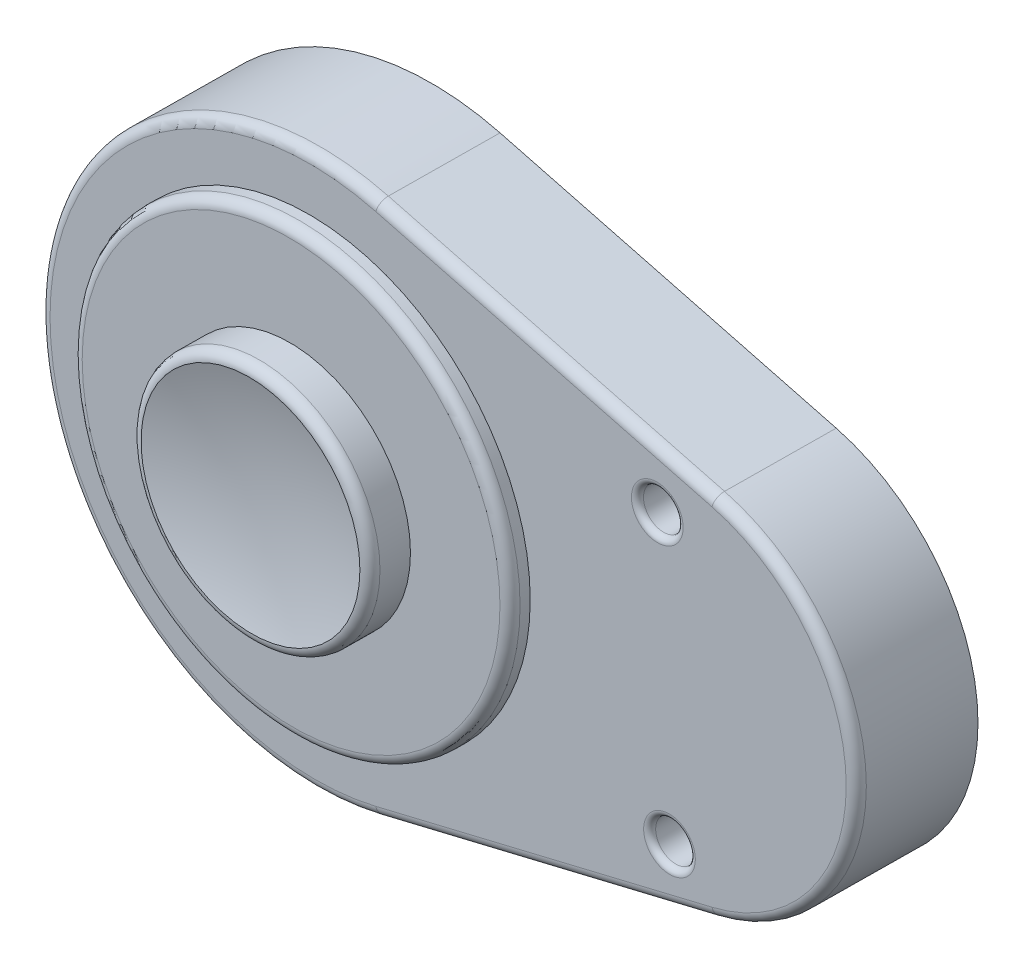
from build123d import *

# Parameters (mm, degrees)
BOSS_EXTRUDE1_DEPTH = 30
SKETCH2_R           = 55
BOSS_EXTRUDE2_DEPTH = 5
SKETCH3_R           = 30
BOSS_EXTRUDE3_DEPTH = 10
SKETCH4_R           = 5
CUT_EXTRUDE4_DEPTH  = 20
SKETCH5_R           = 3
CUT_EXTRUDE5_DEPTH  = 33.082590237
FILLET1_R           = 2.5
FILLET2_R           = 1.5
DOME1_FACE_RADIUS   = 27.5
DOME1_HEIGHT        = 4


with BuildPart() as part:
    # Sketch1 → Boss-Extrude1 (new body)
    with BuildSketch(Plane(origin=(-0.609266147, 0, 59.996906543), x_dir=(0.99993435, 0.005309042, 0.010154293), z_dir=(-0.010154436, 0, 0.999948442))):
        with BuildLine():
            Line((13.092334874, 339.479342253), (-71.283345055, 360.871198017))
            ThreePointArc((-71.283345055, 360.871198017), (-156.616646458, 294.835639545), (-71.989316722, 227.897740169))
            Line((-71.989316722, 227.897740169), (12.608744127, 248.392494546))
            ThreePointArc((12.608744127, 248.392494546), (48.482712148, 293.74674302), (13.092334874, 339.479342253))
        make_face()
    extrude(amount=BOSS_EXTRUDE1_DEPTH)

    # Sketch2 → Boss-Extrude2 (add)
    with BuildSketch(Plane(origin=(-0.91389922, 0, 89.995359815), x_dir=(0.99993435, 0.005309042, 0.010154293), z_dir=(-0.010154436, 0, 0.999948442))):
        with Locations((-88.433233056, 294.473645815)):
            Circle(SKETCH2_R)
    extrude(amount=BOSS_EXTRUDE2_DEPTH)

    # Sketch3 → Boss-Extrude3 (add)
    with BuildSketch(Plane(origin=(-0.964671399, 0, 94.995102027), x_dir=(0.99993435, 0.005309042, 0.010154293), z_dir=(-0.010154436, 0, 0.999948442))):
        with Locations((-88.433233056, 294.473645815)):
            Circle(SKETCH3_R)
    extrude(amount=BOSS_EXTRUDE3_DEPTH)

    # Sketch4 → Cut-Extrude4 (cut)
    with BuildSketch(Plane(origin=(-0.91389922, 0, 89.995359815), x_dir=(0.99993435, 0.005309042, 0.010154293), z_dir=(-0.010154436, 0, 0.999948442))):
        with Locations((-1.318283572, 329.011635606)):
            Circle(SKETCH4_R)
        with Locations((1.375398384, 259.063482824)):
            Circle(SKETCH4_R)
    extrude(amount=-CUT_EXTRUDE4_DEPTH, mode=Mode.SUBTRACT)

    # Sketch5 → Cut-Extrude5 (cut, through all)
    with BuildSketch(Plane(origin=(-0.91389922, 0, 89.995359815), x_dir=(0.99993435, 0.005309042, 0.010154293), z_dir=(-0.010154436, 0, 0.999948442))):
        with Locations((-1.318283572, 329.011635606)):
            Circle(SKETCH5_R)
        with Locations((1.375398384, 259.063482824)):
            Circle(SKETCH5_R)
    extrude(amount=-CUT_EXTRUDE5_DEPTH, mode=Mode.SUBTRACT)

    # Fillet1
    fillet1_edges = [part.edges().sort_by_distance(p)[0] for p in [
        (-159.085477995, 294, 88.389133863),
        (-145.951780521, 293.708002671, 93.522763829),
        (-31.866493678, 237.984134176, 89.681037477),
        (-121.054966127, 293.84072873, 103.776105569),
        (46.006196549, 294, 90.47183148),
        (-31.866493678, 350.015865824, 89.681037477),
    ]]
    fillet(fillet1_edges, radius=FILLET1_R)

    # Fillet2
    fillet2_edges = [part.edges().sort_by_distance(p)[0] for p in [
        (-8.978414644, 328.973454788, 89.913464989),
        (-5.91357097, 259.040588662, 89.944588352),
    ]]
    fillet(fillet2_edges, radius=FILLET2_R)

    # Dome1: a dome of height H over a round flat face of radius A is a cap of a sphere of radius (A * A + H * H) / (2 * H)
    dome1_r = (DOME1_FACE_RADIUS * DOME1_FACE_RADIUS + DOME1_HEIGHT * DOME1_HEIGHT) / (2 * DOME1_HEIGHT)
    dome1_base = Plane((-91.056935626, 294, 104.080734349), z_dir=(0.010154436, 0, -0.999948442))
    with Locations(dome1_base.offset(DOME1_HEIGHT - dome1_r)):
        dome1_ball = Sphere(dome1_r, mode=Mode.PRIVATE)
    add(split(dome1_ball, bisect_by=dome1_base, keep=Keep.TOP, mode=Mode.PRIVATE), mode=Mode.SUBTRACT)


solid = part.part
